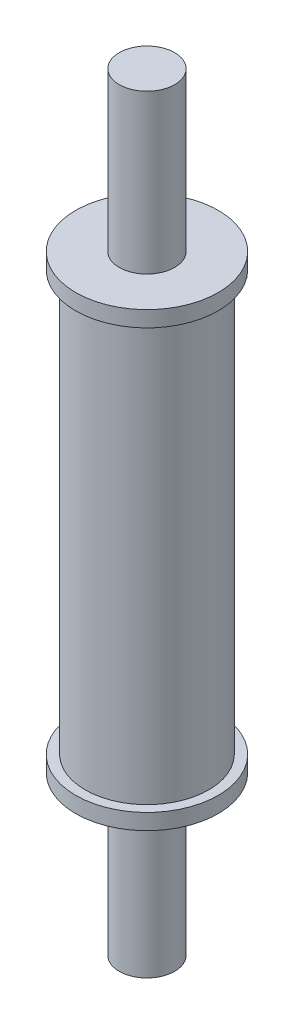
from build123d import *

# Parameters (mm, degrees)
EXTRUDE2_DEPTH          = 28.5
EXTRUDE2_DEPTH_BACK     = 28.5
SKETCH3_R               = 9
CUT_EXTRUDE2_DEPTH      = 26.5
CUT_EXTRUDE2_DEPTH_BACK = 26.5
SKETCH4_R               = 9
SKETCH4_R_2             = 7.8
EXTRUDE3_DEPTH          = 48.5
EXTRUDE3_DEPTH_BACK     = 48.5
SKETCH5_R               = 3.5


with BuildPart() as part:
    # Sketch3 → Extrude2 (new, two sides: drawn at the far end of the back side and taken through both)
    with BuildSketch(Plane(origin=(0, 0, 0), x_dir=(1, 0, 0), z_dir=(0, 1, 0)).offset(-EXTRUDE2_DEPTH_BACK)):
        Circle(SKETCH3_R)
    extrude(amount=EXTRUDE2_DEPTH + EXTRUDE2_DEPTH_BACK)

    # Sketch4 → Cut-Extrude2 (cut, two sides: drawn at the far end of the back side and taken through both)
    with BuildSketch(Plane(origin=(0, 0, 0), x_dir=(1, 0, 0), z_dir=(0, 1, 0)).offset(-CUT_EXTRUDE2_DEPTH_BACK)):
        Circle(SKETCH4_R)
        Circle(SKETCH4_R_2, mode=Mode.SUBTRACT)
    extrude(amount=CUT_EXTRUDE2_DEPTH + CUT_EXTRUDE2_DEPTH_BACK, mode=Mode.SUBTRACT)

    # Sketch5 → Extrude3 (add, two sides: drawn at the far end of the back side and taken through both)
    with BuildSketch(Plane(origin=(0, 0, 0), x_dir=(1, 0, 0), z_dir=(0, 1, 0)).offset(-EXTRUDE3_DEPTH_BACK)):
        Circle(SKETCH5_R)
    extrude(amount=EXTRUDE3_DEPTH + EXTRUDE3_DEPTH_BACK)


solid = part.part
